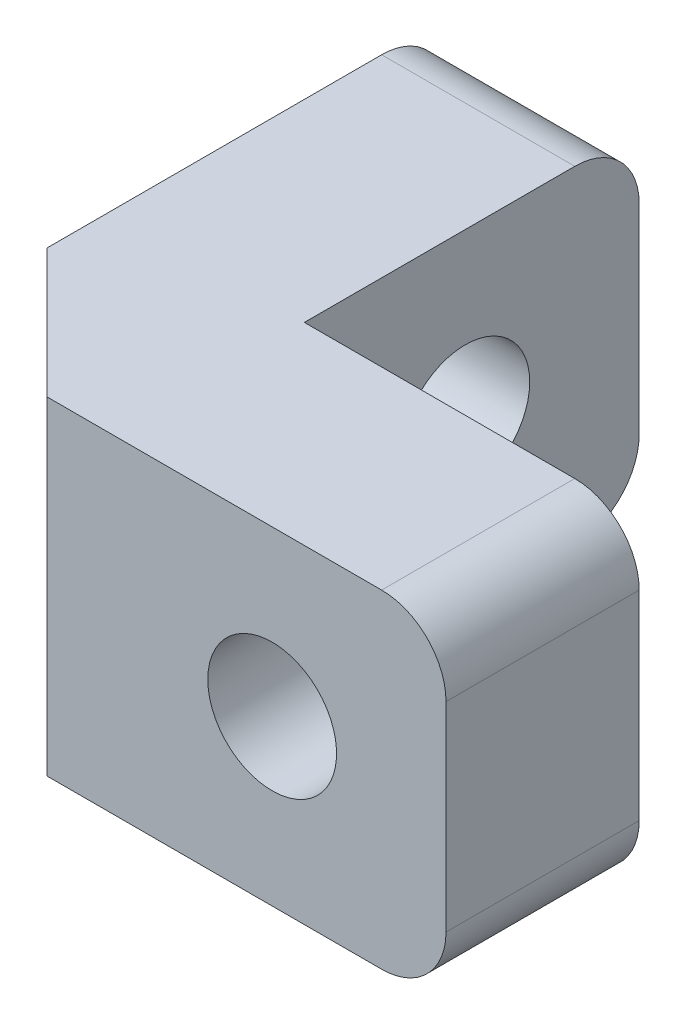
from build123d import *

# Parameters (mm, degrees)
BOSS_EXTRUDE1_DEPTH = 5.1
CHAMFER1_SIZE       = 2
FILLET1_R           = 1
SKETCH3_R           = 1
CUT_EXTRUDE1_DEPTH  = 5.1
SKETCH4_R           = 1
CUT_EXTRUDE2_DEPTH  = 5.1
SKETCH5_R           = 1.7
CUT_EXTRUDE3_DEPTH  = 1.4
SKETCH6_R           = 1.7
CUT_EXTRUDE4_DEPTH  = 1.4


with BuildPart() as part:
    # Sketch1 → Boss-Extrude1 (new body)
    with BuildSketch(Plane(origin=(0, 0, 0), x_dir=(1, 0, 0), z_dir=(0, 1, 0))):
        Polygon((0, 0), (0, 5.2), (-3, 5.2), (-3, -3), (5.2, -3), (5.2, 0), align=None)
    extrude(amount=BOSS_EXTRUDE1_DEPTH)

    # Chamfer1
    chamfer1_edges = [part.edges().sort_by_distance(p)[0] for p in [
        (-3, 2.55, 3),
    ]]
    chamfer(chamfer1_edges, length=CHAMFER1_SIZE)

    # Fillet1
    fillet1_edges = [part.edges().sort_by_distance(p)[0] for p in [
        (-1.5, 5.1, -5.2),
        (5.2, 5.1, 1.5),
        (5.2, 0, 1.5),
        (-1.5, 0, -5.2),
    ]]
    fillet(fillet1_edges, radius=FILLET1_R)

    # Sketch3 → Cut-Extrude1 (cut)
    with BuildSketch(Plane(origin=(0, 0, 0), x_dir=(0, 0, -1), z_dir=(1, 0, 0))):
        with Locations((2.5, 2.55)):
            Circle(SKETCH3_R)
    extrude(amount=-CUT_EXTRUDE1_DEPTH, mode=Mode.SUBTRACT)

    # Sketch4 → Cut-Extrude2 (cut)
    with BuildSketch(Plane(origin=(0, 0, 0), x_dir=(-1, 0, 0), z_dir=(0, 0, -1))):
        with Locations((-2.5, 2.55)):
            Circle(SKETCH4_R)
    extrude(amount=-CUT_EXTRUDE2_DEPTH, mode=Mode.SUBTRACT)

    # Sketch5 → Cut-Extrude3 (cut)
    with BuildSketch(Plane(origin=(0, 0, 0), x_dir=(-1, 0, 0), z_dir=(0, 0, -1))):
        with Locations((-2.5, 2.55)):
            Circle(SKETCH5_R)
    extrude(amount=-CUT_EXTRUDE3_DEPTH, mode=Mode.SUBTRACT)

    # Sketch6 → Cut-Extrude4 (cut)
    with BuildSketch(Plane.ZY.offset(3)):
        with Locations((-2.5, 2.55)):
            Circle(SKETCH6_R)
    extrude(amount=-CUT_EXTRUDE4_DEPTH, mode=Mode.SUBTRACT)


solid = part.part
